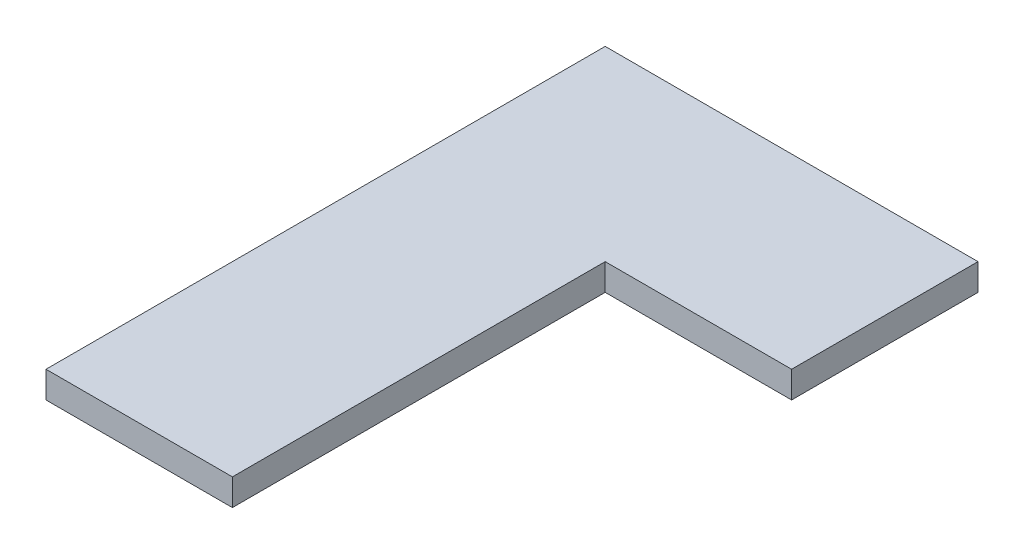
from build123d import *

# Parameters (mm, degrees)
BOSS_EXTRUDE1_DEPTH = 10


with BuildPart() as part:
    # Sketch1 → Boss-Extrude1 (new body)
    with BuildSketch(Plane(origin=(0, 0, 0), x_dir=(1, 0, 0), z_dir=(0, 1, 0))):
        Polygon((0, -105), (0, 35), (70, 35), (70, 105), (-70, 105), (-70, -105), align=None)
    extrude(amount=BOSS_EXTRUDE1_DEPTH)


solid = part.part
